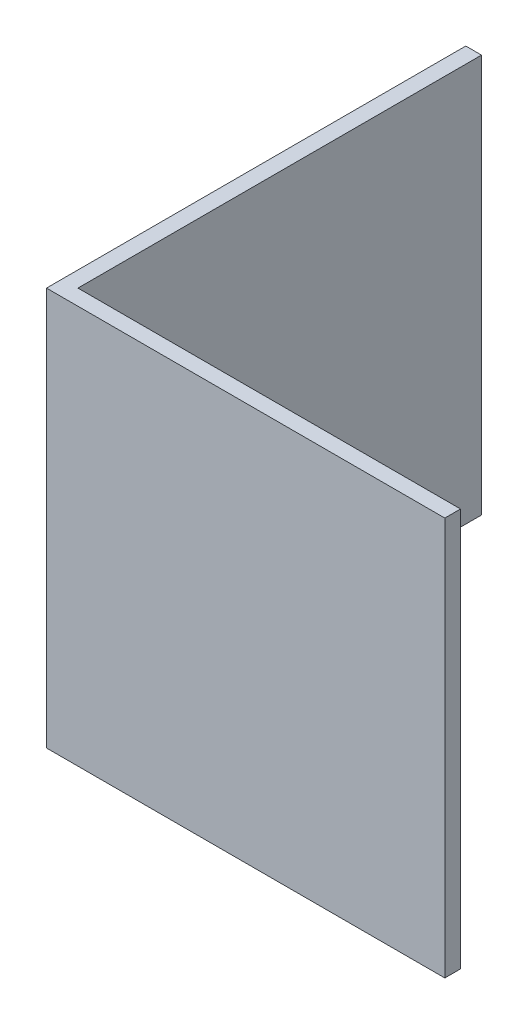
from build123d import *

# Parameters (mm, degrees)
EXTRUDE_1_DEPTH     = 19
SKETCH_2_W          = 0.75
SKETCH_2_H          = 19
CUT_EXTRUDE_1_DEPTH = 1


with BuildPart() as part:
    # Эскиз1 → Бобышка-Вытянуть1 (new body)
    with BuildSketch(Plane(origin=(0, 0, 0), x_dir=(1, 0, 0), z_dir=(0, 1, 0))):
        Polygon((0, 0), (0, 20), (0.75, 20), (0.75, 0.75), (20, 0.75), (20, 0), align=None)
    extrude(amount=EXTRUDE_1_DEPTH)

    # Эскиз2 → Вырез-Вытянуть1 (cut)
    with BuildSketch(Plane(origin=(20, 0, 0), x_dir=(0, 0, -1), z_dir=(1, 0, 0))):
        with Locations((0.375, 9.5)):
            Rectangle(SKETCH_2_W, SKETCH_2_H)
    extrude(amount=-CUT_EXTRUDE_1_DEPTH, mode=Mode.SUBTRACT)


solid = part.part
